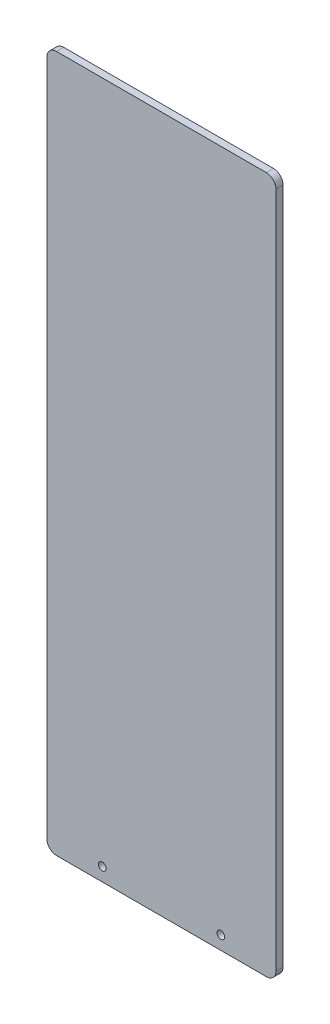
from build123d import *

# Parameters (mm, degrees)
SKETCH1_W           = 152.4
SKETCH1_H           = 463.55
BOSS_EXTRUDE1_DEPTH = 4.7625
FILLET1_R           = 6.35
SKETCH2_R           = 2.54
CUT_EXTRUDE1_DEPTH  = 7.62


with BuildPart() as part:
    # Sketch1 → Boss-Extrude1 (new body)
    with BuildSketch(Plane.XY):
        with Locations((76.2, 231.775)):
            Rectangle(SKETCH1_W, SKETCH1_H)
    extrude(amount=BOSS_EXTRUDE1_DEPTH)

    # Fillet1
    fillet1_edges = [part.edges().sort_by_distance(p)[0] for p in [
        (0, 463.55, 2.38125),
        (152.4, 463.55, 2.38125),
        (152.4, 0, 2.38125),
        (0, 0, 2.38125),
    ]]
    fillet(fillet1_edges, radius=FILLET1_R)

    # Sketch2 → Cut-Extrude1 (cut)
    with BuildSketch(Plane.XY.offset(4.7625)):
        with Locations((36.83, 8.9535)):
            Circle(SKETCH2_R)
        with Locations((115.73288862, 8.9535)):
            Circle(SKETCH2_R)
    extrude(amount=-CUT_EXTRUDE1_DEPTH, mode=Mode.SUBTRACT)


solid = part.part
